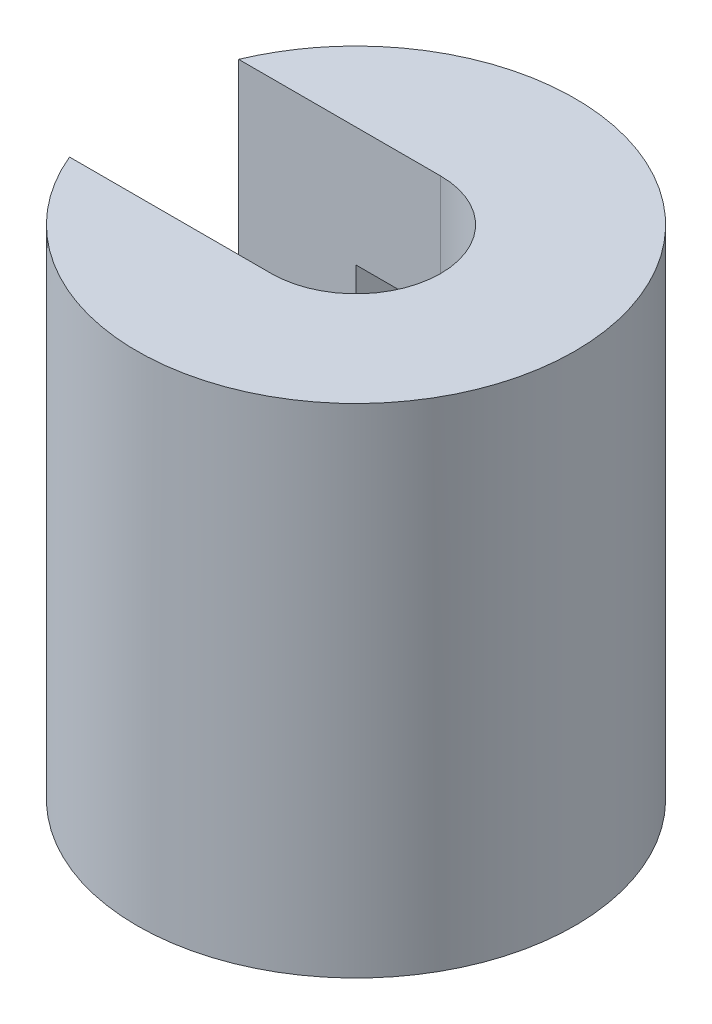
from build123d import *

# Parameters (mm, degrees)
CROQUIS1_R              = 11
SALIENTE_EXTRUIR1_DEPTH = 25
CROQUIS2_R              = 4.25
CORTAR_EXTRUIR1_DEPTH   = 5
CROQUIS3_R              = 4.25
CORTAR_EXTRUIR2_DEPTH   = 6
CROQUIS5_W              = 8.5
CROQUIS5_H              = 15.5
CORTAR_EXTRUIR8_DEPTH   = 10
CORTAR_EXTRUIR16_DEPTH  = 12


with BuildPart() as part:
    # Croquis1 → Saliente-Extruir1 (new body)
    with BuildSketch(Plane(origin=(0, 0, 0), x_dir=(1, 0, 0), z_dir=(0, 1, 0))):
        Circle(CROQUIS1_R)
    extrude(amount=SALIENTE_EXTRUIR1_DEPTH)

    # Croquis2 → Cortar-Extruir1 (cut)
    with BuildSketch(Plane.XZ):
        Circle(CROQUIS2_R)
    extrude(amount=-CORTAR_EXTRUIR1_DEPTH, mode=Mode.SUBTRACT)

    # Croquis3 → Cortar-Extruir2 (cut)
    with BuildSketch(Plane(origin=(0, 25, 0), x_dir=(1, 0, 0), z_dir=(0, 1, 0))):
        Circle(CROQUIS3_R)
    extrude(amount=-CORTAR_EXTRUIR2_DEPTH, mode=Mode.SUBTRACT)

    # Croquis5 → Cortar-Extruir8 (cut)
    with BuildSketch(Plane(origin=(0, 19, 0), x_dir=(1, 0, 0), z_dir=(0, 1, 0))):
        Rectangle(CROQUIS5_W, CROQUIS5_H)
    extrude(amount=-CORTAR_EXTRUIR8_DEPTH, mode=Mode.SUBTRACT)

    # Croquis9 → Cortar-Extruir16 (cut, through all)
    with BuildSketch(Plane(origin=(0, 0, 0), x_dir=(0, 0, -1), z_dir=(1, 0, 0))):
        Polygon((-7.75, 9), (7.75, 9), (7.75, 14.5), (4.25, 14.5), (4.25, 25.5), (-4.25, 25.5), (-4.25, 14.5), (-7.75, 14.5), align=None)
    extrude(amount=-CORTAR_EXTRUIR16_DEPTH, mode=Mode.SUBTRACT)


solid = part.part
